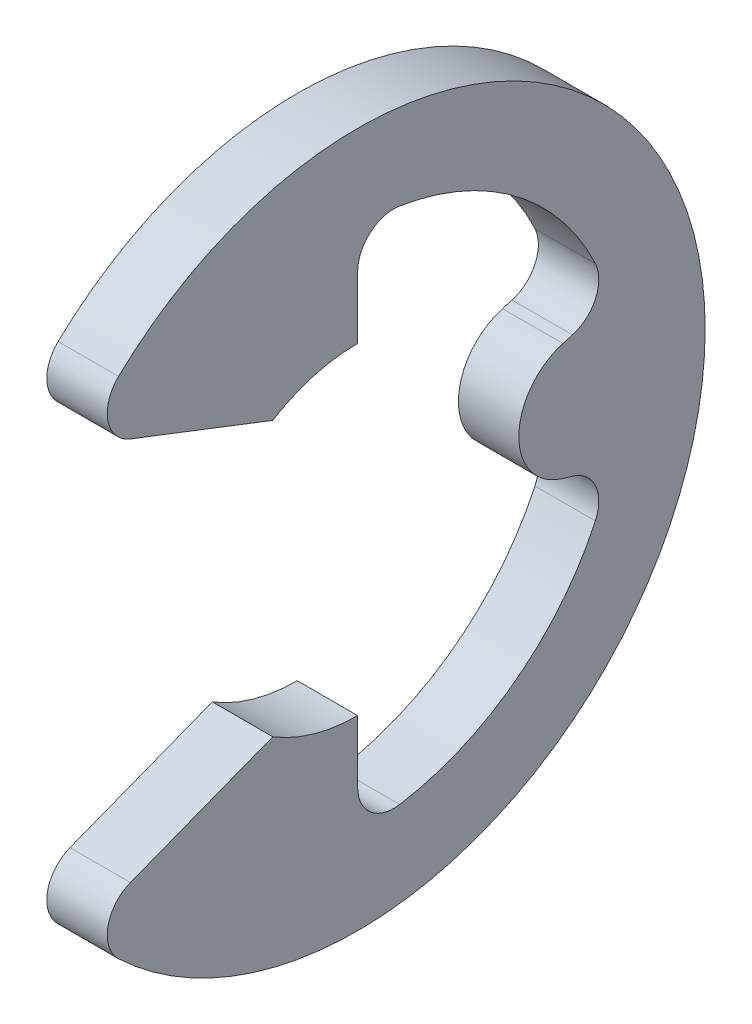
from build123d import *

# Parameters (mm, degrees)
EXTRUDE1_DEPTH          = 0.3
FILLET1_R               = 0.36
CUT_EXTRUDE1_DEPTH      = 5.888251221
CUT_EXTRUDE1_DEPTH_BACK = 5.888251221


with BuildPart() as part:
    # Sketch1 → Extrude1 (new, symmetric)
    with BuildSketch(Plane(origin=(0, 0, 0), x_dir=(0, 0, -1), z_dir=(1, 0, 0))):
        with BuildLine():
            Line((-2.741249311, -2.094767819), (-0.8428523, -1.36))
            ThreePointArc((-0.8428523, -1.36), (-0.438178046, -1.538830725), (0, -1.6))
            Line((0, -1.6), (0, -2.606451613))
            ThreePointArc((0, -2.606451613), (1.570523601, -2.080155193), (2.506804891, -0.713806172))
            Line((2.506804891, -0.713806172), (1.538830725, -0.438178046))
            ThreePointArc((1.538830725, -0.438178046), (1.6, 0), (1.538830725, 0.438178046))
            Line((1.538830725, 0.438178046), (2.506804891, 0.713806172))
            ThreePointArc((2.506804891, 0.713806172), (1.570523601, 2.080155193), (0, 2.606451613))
            Line((0, 2.606451613), (0, 1.6))
            ThreePointArc((0, 1.6), (-0.438178046, 1.538830725), (-0.8428523, 1.36))
            Line((-0.8428523, 1.36), (-2.741249311, 2.094767819))
            ThreePointArc((-2.741249311, 2.094767819), (3.45, 0), (-2.741249311, -2.094767819))
        make_face()
    extrude(amount=EXTRUDE1_DEPTH, both=True)

    # Fillet1
    fillet1_edges = [part.edges().sort_by_distance(p)[0] for p in [
        (0, -2.606451613, 0),
        (0, 2.606451613, 0),
        (0, -2.094767819, 2.741249311),
        (0, 2.094767819, 2.741249311),
        (0, -0.713806172, -2.506804891),
        (0, 0.713806172, -2.506804891),
    ]]
    fillet(fillet1_edges, radius=FILLET1_R)

    # Sketch4 → Cut-Extrude1 (cut, two sides: drawn at the far end of the back side and taken through both)
    with BuildSketch(Plane(origin=(0, 0, 0), x_dir=(0, 0, -1), z_dir=(1, 0, 0)).offset(-CUT_EXTRUDE1_DEPTH_BACK)):
        with BuildLine():
            ThreePointArc((1.6, 0), (1.584633895, -0.221213517), (1.538830725, -0.438178046))
            Line((1.538830725, -0.438178046), (2.038178046, -0.580365897))
            ThreePointArc((2.038178046, -0.580365897), (1.721846138, -0.363601628), (1.6, 0))
        make_face()
        with BuildLine():
            ThreePointArc((1.538830725, 0.438178046), (1.584633895, 0.221213517), (1.6, 0))
            ThreePointArc((1.6, 0), (1.721846138, 0.363601628), (2.038178046, 0.580365897))
            Line((2.038178046, 0.580365897), (1.538830725, 0.438178046))
        make_face()
    extrude(amount=CUT_EXTRUDE1_DEPTH + CUT_EXTRUDE1_DEPTH_BACK, mode=Mode.SUBTRACT)


solid = part.part
